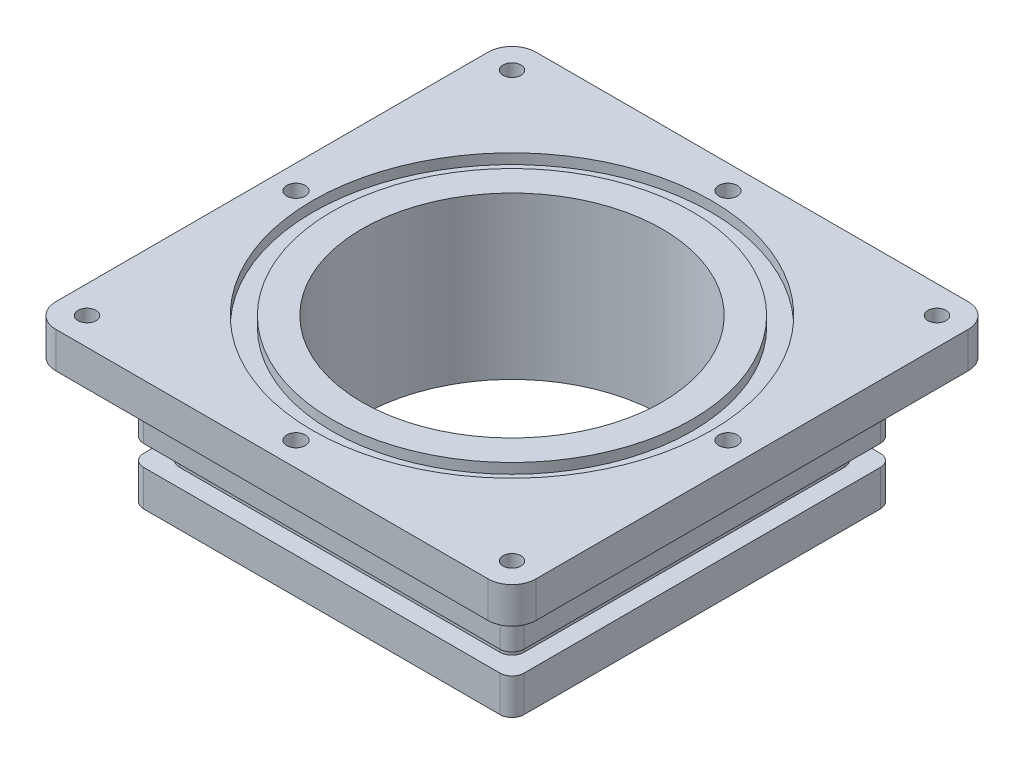
from build123d import *

# Parameters (mm, degrees)
SKETCH_3_W               = 80
SKETCH_3_H               = 80
EXTRUDE_1_DEPTH          = 6
SKETCH_4_W               = 63.4
SKETCH_4_H               = 63.4
EXTRUDE_2_DEPTH          = 4
SKETCH_5_W               = 57.4
SKETCH_5_H               = 57.4
EXTRUDE_3_DEPTH          = 3.45
SKETCH_6_W               = 63.4
SKETCH_6_H               = 63.4
EXTRUDE_4_DEPTH          = 4
SKETCH_7_W               = 57.4
SKETCH_7_H               = 57.4
EXTRUDE_5_DEPTH          = 3.45
SKETCH_8_W               = 63.4
SKETCH_8_H               = 63.4
EXTRUDE_6_DEPTH          = 6
CUT_EXTRUDE_3_DEPTH      = 63.638726041
CUT_EXTRUDE_3_DEPTH_BACK = 63.638726041
SKETCH_11_R              = 25
SKETCH_12_R              = 33.2
SKETCH_12_R_2            = 30
CUT_EXTRUDE_4_DEPTH      = 1.7
SKETCH_13_R              = 1.55
CUT_EXTRUDE_5_DEPTH      = 6
PATTERN_CIRCULAR_1_COUNT = 4
SKETCH_14_R              = 1.5
CUT_EXTRUDE_6_DEPTH      = 6
PATTERN_CIRCULAR_2_COUNT = 4
CUT_EXTRUDE_7_DEPTH      = 3
PATTERN_CIRCULAR_3_COUNT = 4
FILLET_1_R               = 2
FILLET_2_R               = 4


with BuildPart() as part:
    # 草图3 → 凸台-拉伸1 (new body)
    with BuildSketch(Plane(origin=(0, 0, 0), x_dir=(1, 0, 0), z_dir=(0, 1, 0))):
        Rectangle(SKETCH_3_W, SKETCH_3_H)
    extrude(amount=EXTRUDE_1_DEPTH)

    # 草图4 → 凸台-拉伸2 (add)
    with BuildSketch(Plane(origin=(0, 0, 0), x_dir=(-1, 0, 0), z_dir=(0, -1, 0))):
        Rectangle(SKETCH_4_W, SKETCH_4_H)
    extrude(amount=EXTRUDE_2_DEPTH)

    # 草图5 → 凸台-拉伸3 (add)
    with BuildSketch(Plane(origin=(0, -4, 0), x_dir=(-1, 0, 0), z_dir=(0, -1, 0))):
        Rectangle(SKETCH_5_W, SKETCH_5_H)
    extrude(amount=EXTRUDE_3_DEPTH)

    # 草图6 → 凸台-拉伸4 (add)
    with BuildSketch(Plane(origin=(0, -7.45, 0), x_dir=(-1, 0, 0), z_dir=(0, -1, 0))):
        Rectangle(SKETCH_6_W, SKETCH_6_H)
    extrude(amount=EXTRUDE_4_DEPTH)

    # 草图7 → 凸台-拉伸5 (add)
    with BuildSketch(Plane(origin=(0, -11.45, 0), x_dir=(-1, 0, 0), z_dir=(0, -1, 0))):
        Rectangle(SKETCH_7_W, SKETCH_7_H)
    extrude(amount=EXTRUDE_5_DEPTH)

    # 草图8 → 凸台-拉伸6 (add)
    with BuildSketch(Plane(origin=(0, -14.9, 0), x_dir=(-1, 0, 0), z_dir=(0, -1, 0))):
        Rectangle(SKETCH_8_W, SKETCH_8_H)
    extrude(amount=EXTRUDE_6_DEPTH)

    # 草图11 → 切除-拉伸3 (cut, two sides: drawn at the far end of the back side and taken through both)
    with BuildSketch(Plane(origin=(0, 6, 0), x_dir=(1, 0, 0), z_dir=(0, 1, 0)).offset(-CUT_EXTRUDE_3_DEPTH_BACK)):
        Circle(SKETCH_11_R)
    extrude(amount=CUT_EXTRUDE_3_DEPTH + CUT_EXTRUDE_3_DEPTH_BACK, mode=Mode.SUBTRACT)

    # 草图12 → 切除-拉伸4 (cut)
    with BuildSketch(Plane(origin=(0, 6, 0), x_dir=(1, 0, 0), z_dir=(0, 1, 0))):
        Circle(SKETCH_12_R)
        Circle(SKETCH_12_R_2, mode=Mode.SUBTRACT)
    extrude(amount=-CUT_EXTRUDE_4_DEPTH, mode=Mode.SUBTRACT)

    # 草图13 → 切除-拉伸5 (cut)
    with BuildSketch(Plane(origin=(0, 6, 0), x_dir=(1, 0, 0), z_dir=(0, 1, 0))):
        with Locations((0, 36)):
            Circle(SKETCH_13_R)
    cut_extrude_5 = extrude(amount=-CUT_EXTRUDE_5_DEPTH, mode=Mode.SUBTRACT)

    # 阵列(圆周)1: 切除-拉伸5 ×4 about axis
    pattern_circular_1_axis = Axis((0, 55, 0), (0, -1, 0))
    for i in range(1, PATTERN_CIRCULAR_1_COUNT):
        add(cut_extrude_5.rotate(pattern_circular_1_axis, i * 360 / PATTERN_CIRCULAR_1_COUNT), mode=Mode.SUBTRACT)

    # 草图14 → 切除-拉伸6 (cut)
    with BuildSketch(Plane(origin=(0, 6, 0), x_dir=(1, 0, 0), z_dir=(0, 1, 0))):
        with Locations((-35.403805922, 35.403805922)):
            Circle(SKETCH_14_R)
    cut_extrude_6 = extrude(amount=-CUT_EXTRUDE_6_DEPTH, mode=Mode.SUBTRACT)

    # 阵列(圆周)2: 切除-拉伸6 ×4 about axis
    pattern_circular_2_axis = Axis((0, 55, 0), (0, -1, 0))
    for i in range(1, PATTERN_CIRCULAR_2_COUNT):
        add(cut_extrude_6.rotate(pattern_circular_2_axis, i * 360 / PATTERN_CIRCULAR_2_COUNT), mode=Mode.SUBTRACT)

    # 草图15 → 切除-拉伸7 (cut)
    with BuildSketch(Plane(origin=(0, 0, 0), x_dir=(-1, 0, 0), z_dir=(0, -1, 0))):
        Polygon((1.615900042, 33.199607101), (3.233161412, 35.999214037), (1.61726137, 38.799606936), (-1.615900042, 38.800392899), (-3.233161412, 36.000785963), (-1.61726137, 33.200393064), align=None)
        Polygon((-37.689996349, 37.689996349), (-38.526800123, 34.567002148), (-36.240609696, 32.280811722), (-33.117615496, 33.117615496), (-32.280811722, 36.240609696), (-34.567002148, 38.526800123), align=None)
    cut_extrude_7 = extrude(amount=-CUT_EXTRUDE_7_DEPTH, mode=Mode.SUBTRACT)

    # 阵列(圆周)3: 切除-拉伸7 ×4 about axis
    pattern_circular_3_axis = Axis((0, 55, 0), (0, -1, 0))
    for i in range(1, PATTERN_CIRCULAR_3_COUNT):
        add(cut_extrude_7.rotate(pattern_circular_3_axis, i * 360 / PATTERN_CIRCULAR_3_COUNT), mode=Mode.SUBTRACT)

    # 圆角1
    fillet_1_edges = [part.edges().sort_by_distance(p)[0] for p in [
        (31.7, -2, 31.7),
        (28.7, -5.725, 28.7),
        (31.7, -9.45, 31.7),
        (28.7, -13.175, 28.7),
        (31.7, -17.9, 31.7),
        (31.7, -2, -31.7),
        (28.7, -5.725, -28.7),
        (31.7, -9.45, -31.7),
        (28.7, -13.175, -28.7),
        (31.7, -17.9, -31.7),
        (-31.7, -2, -31.7),
        (-28.7, -5.725, -28.7),
        (-31.7, -9.45, -31.7),
        (-28.7, -13.175, -28.7),
        (-31.7, -17.9, -31.7),
        (-31.7, -17.9, 31.7),
        (-28.7, -13.175, 28.7),
        (-31.7, -9.45, 31.7),
        (-28.7, -5.725, 28.7),
        (-31.7, -2, 31.7),
    ]]
    fillet(fillet_1_edges, radius=FILLET_1_R)

    # 圆角2
    fillet_2_edges = [part.edges().sort_by_distance(p)[0] for p in [
        (40, 3, 40),
        (40, 3, -40),
        (-40, 3, 40),
        (-40, 3, -40),
    ]]
    fillet(fillet_2_edges, radius=FILLET_2_R)


solid = part.part
